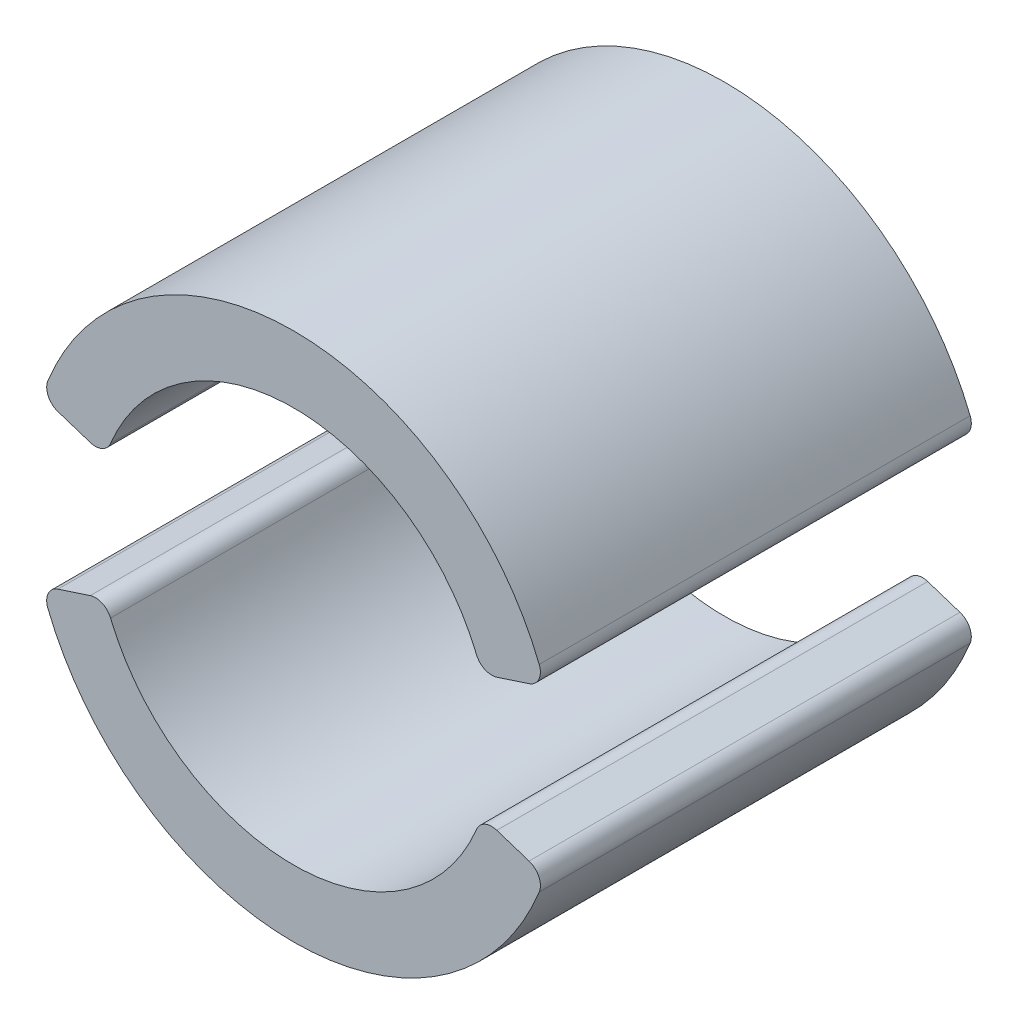
from build123d import *

# Parameters (mm, degrees)
BOSS_EXTRUDE1_DEPTH   = 26.67
BOSS_EXTRUDE1_2_DEPTH = 26.67


with BuildPart() as part:
    # Sketch1 → Boss-Extrude1 (new body)
    with BuildSketch(Plane.XY):
        with BuildLine():
            Line((-12.580337264, 4.103117178), (-14.577613892, 4.75453533))
            ThreePointArc((-14.577613892, 4.75453533), (-15.183079054, 5.290424814), (-15.205555307, 6.098670085))
            ThreePointArc((-15.205555307, 6.098670085), (0, 16.383), (15.205555307, 6.098670085))
            ThreePointArc((15.205555307, 6.098670085), (15.183079054, 5.290424814), (14.577613892, 4.75453533))
            Line((14.577613892, 4.75453533), (12.580337264, 4.103117178))
            ThreePointArc((12.580337264, 4.103117178), (11.840088209, 4.146298157), (11.326328284, 4.68097937))
            ThreePointArc((11.326328284, 4.68097937), (0, 12.2555), (-11.326328284, 4.68097937))
            ThreePointArc((-11.326328284, 4.68097937), (-11.840088209, 4.146298157), (-12.580337264, 4.103117178))
        make_face()
    extrude(amount=BOSS_EXTRUDE1_DEPTH)


with BuildPart() as body_2:
    # Sketch1 → Boss-Extrude1 2 (new body)
    with BuildSketch(Plane.XY):
        with BuildLine():
            Line((12.580337264, -4.103117178), (14.577613892, -4.75453533))
            ThreePointArc((14.577613892, -4.75453533), (15.183079054, -5.290424814), (15.205555307, -6.098670085))
            ThreePointArc((15.205555307, -6.098670085), (0, -16.383), (-15.205555307, -6.098670085))
            ThreePointArc((-15.205555307, -6.098670085), (-15.183079054, -5.290424814), (-14.577613892, -4.75453533))
            Line((-14.577613892, -4.75453533), (-12.580337264, -4.103117178))
            ThreePointArc((-12.580337264, -4.103117178), (-11.840088209, -4.146298157), (-11.326328284, -4.68097937))
            ThreePointArc((-11.326328284, -4.68097937), (0, -12.2555), (11.326328284, -4.68097937))
            ThreePointArc((11.326328284, -4.68097937), (11.840088209, -4.146298157), (12.580337264, -4.103117178))
        make_face()
    extrude(amount=BOSS_EXTRUDE1_2_DEPTH)


solid = Compound([part.part, body_2.part])
